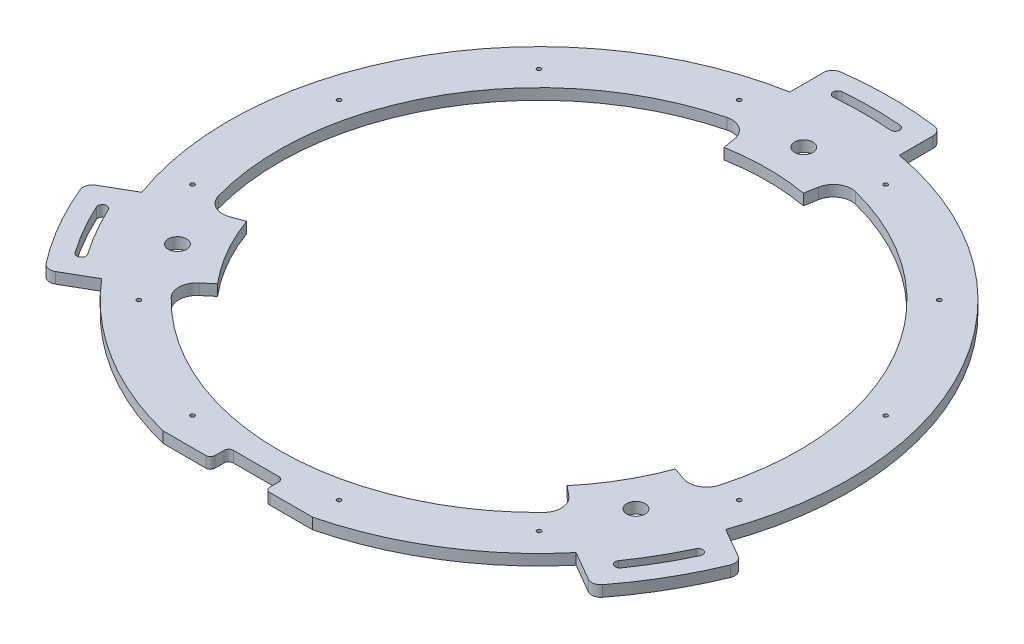
from build123d import *

# Parameters (mm, degrees)
SKETCH1_R                                      = 340
SKETCH1_R_2                                    = 250
BOSS_EXTRUDE1_DEPTH                            = 12
BOSS_EXTRUDE2_DEPTH                            = 12
CIRPATTERN1_COUNT                              = 3
CUT_EXTRUDE1_DEPTH                             = 12
CIRPATTERN2_COUNT                              = 3
CUT_EXTRUDE2_DEPTH                             = 12
SKETCH8_R                                      = 10
CUT_EXTRUDE3_DEPTH                             = 12
SKETCH9_W                                      = 60
SKETCH9_H                                      = 20
CUT_EXTRUDE4_DEPTH                             = 12
FILLET1_R                                      = 5
CSK_FOR_M4_FLAT_HEAD_MACHINE_SCREW_D           = 4.5
CSK_FOR_M4_FLAT_HEAD_MACHINE_SCREW_CSINK_D     = 9.4
CSK_FOR_M4_FLAT_HEAD_MACHINE_SCREW_CSINK_ANGLE = 90


with BuildPart() as part:
    # Sketch1 → Boss-Extrude1 (new body)
    with BuildSketch(Plane(origin=(0, 0, 0), x_dir=(1, 0, 0), z_dir=(0, 1, 0))):
        Circle(SKETCH1_R)
        Circle(SKETCH1_R_2, mode=Mode.SUBTRACT)
    extrude(amount=BOSS_EXTRUDE1_DEPTH)

    # Sketch2 → Boss-Extrude2 (add)
    with BuildSketch(Plane.XZ):
        with BuildLine():
            Line((351.85982974, 133.864335114), (319.827534924, 115.37048108))
            ThreePointArc((319.827534924, 115.37048108), (294.448637287, 170), (259.827534924, 219.293529534))
            Line((259.827534924, 219.293529534), (291.85982974, 237.787383569))
            ThreePointArc((291.85982974, 237.787383569), (298.796843602, 238.937734879), (304.776091866, 235.237186318))
            ThreePointArc((304.776091866, 235.237186318), (333.419780457, 192.5), (356.109425199, 146.325244863))
            ThreePointArc((356.109425199, 146.325244863), (356.324570129, 139.29678969), (351.85982974, 133.864335114))
        make_face()
        with BuildLine():
            ThreePointArc((298.990496165, 209.355399268), (316.099272381, 182.5), (330.802342268, 154.255665535))
            ThreePointArc((330.802342268, 154.255665535), (328.383894642, 147.611035291), (321.739264398, 150.029482918))
            ThreePointArc((321.739264398, 150.029482918), (307.439018343, 177.5), (290.798975723, 203.619634905))
            ThreePointArc((290.798975723, 203.619634905), (292.026853762, 210.583277308), (298.990496165, 209.355399268))
        make_face(mode=Mode.SUBTRACT)
    boss_extrude2 = extrude(amount=-BOSS_EXTRUDE2_DEPTH)

    # CirPattern1: Boss-Extrude2 ×3 about axis
    cirpattern1_axis = Axis((0, 0, 0), (0, 1, 0))
    for i in range(1, CIRPATTERN1_COUNT):
        add(boss_extrude2.rotate(cirpattern1_axis, i * 360 / CIRPATTERN1_COUNT))

    # Sketch6 → Cut-Extrude1 (cut)
    with BuildSketch(Plane(origin=(0, 12, 0), x_dir=(1, 0, 0), z_dir=(0, 1, 0))):
        with BuildLine():
            Line((234.923155199, -85.505035825), (248.308329747, -90.37684094))
            ThreePointArc((248.308329747, -90.37684094), (264.279563148, -89.37703061), (274.405240734, -76.985478225))
            ThreePointArc((274.405240734, -76.985478225), (246.817240074, 142.500000006), (70.531240487, 276.134648524))
            ThreePointArc((70.531240487, 276.134648524), (54.737002537, 273.561330696), (45.885524691, 260.229742005))
            Line((45.885524691, 260.229742005), (43.412044408, 246.201938255))
            ThreePointArc((43.412044408, 246.201938255), (216.506350942, 125.000000007), (234.923155199, -85.505035825))
        make_face()
    cut_extrude1 = extrude(amount=-CUT_EXTRUDE1_DEPTH, mode=Mode.SUBTRACT)

    # CirPattern2: Cut-Extrude1 ×3 about axis
    cirpattern2_axis = Axis((0, 0, 0), (0, 1, 0))
    for i in range(1, CIRPATTERN2_COUNT):
        add(cut_extrude1.rotate(cirpattern2_axis, i * 360 / CIRPATTERN2_COUNT), mode=Mode.SUBTRACT)

    # Sketch7 → Cut-Extrude2 (cut)
    with BuildSketch(Plane.XZ):
        with BuildLine():
            Line((-81.853527719, 330), (81.853527719, 330))
            ThreePointArc((81.853527719, 330), (0, 340), (-81.853527719, 330))
        make_face()
    extrude(amount=-CUT_EXTRUDE2_DEPTH, mode=Mode.SUBTRACT)

    # Sketch8 → Cut-Extrude3 (cut)
    with BuildSketch(Plane(origin=(0, 12, 0), x_dir=(1, 0, 0), z_dir=(0, 1, 0))):
        with Locations((0, 290)):
            Circle(SKETCH8_R)
        with Locations((251.147367097, -145)):
            Circle(SKETCH8_R)
        with Locations((-251.147367097, -145)):
            Circle(SKETCH8_R)
    extrude(amount=-CUT_EXTRUDE3_DEPTH, mode=Mode.SUBTRACT)

    # Sketch9 → Cut-Extrude4 (cut)
    with BuildSketch(Plane(origin=(0, 12, 0), x_dir=(1, 0, 0), z_dir=(0, 1, 0))):
        with Locations((0, -320)):
            Rectangle(SKETCH9_W, SKETCH9_H)
    extrude(amount=-CUT_EXTRUDE4_DEPTH, mode=Mode.SUBTRACT)

    # Fillet1
    fillet1_edges = [part.edges().sort_by_distance(p)[0] for p in [
        (30, 6, 330),
        (-30, 6, 330),
        (-30, 6, 310),
        (30, 6, 310),
    ]]
    fillet(fillet1_edges, radius=FILLET1_R)

    # CSK for M4 Flat Head Machine Screw (through all)
    with Locations(Plane(origin=(0, 48, 0), x_dir=(1, 0, 0), z_dir=(0, 1, 0))):
        with Locations((80.233903982, 299.43700615), (219.203102168, 219.203102168), (299.43700615, 80.233903982), (299.43700615, -80.233903982), (219.203102168, -219.203102168), (80.233903982, -299.43700615), (-80.233903982, -299.43700615), (-219.203102168, -219.203102168), (-299.43700615, -80.233903982), (-299.43700615, 80.233903982), (-219.203102168, 219.203102168), (-80.233903982, 299.43700615), (0, 0)):
            CounterSinkHole(CSK_FOR_M4_FLAT_HEAD_MACHINE_SCREW_D / 2, CSK_FOR_M4_FLAT_HEAD_MACHINE_SCREW_CSINK_D / 2, counter_sink_angle=CSK_FOR_M4_FLAT_HEAD_MACHINE_SCREW_CSINK_ANGLE)


solid = part.part
